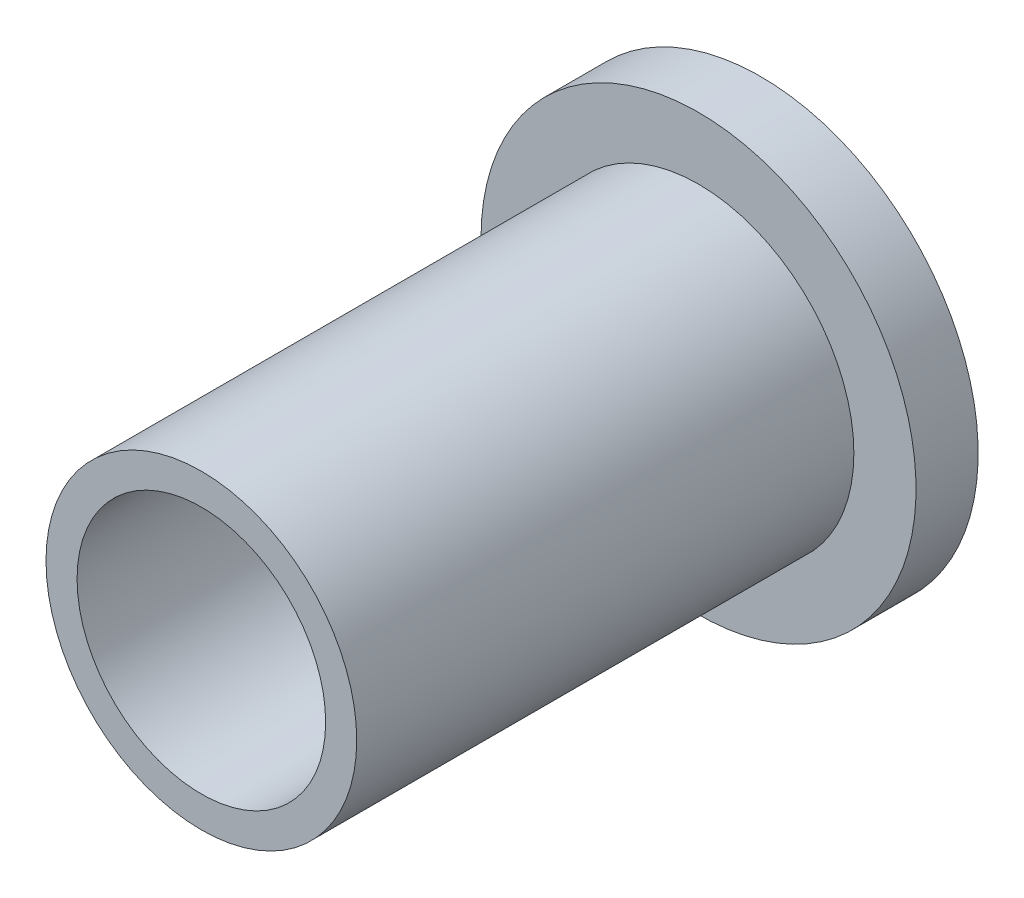
from build123d import *

# Parameters (mm, degrees)
SKETCH1_R           = 7.9375
SKETCH1_R_2         = 6.35
BOSS_EXTRUDE1_DEPTH = 25.4
SKETCH2_R           = 11.1125
SKETCH2_R_2         = 6.35
BOSS_EXTRUDE2_DEPTH = 3.175


with BuildPart() as part:
    # Sketch1 → Boss-Extrude1 (new body)
    with BuildSketch(Plane.XY):
        Circle(SKETCH1_R)
        Circle(SKETCH1_R_2, mode=Mode.SUBTRACT)
    extrude(amount=BOSS_EXTRUDE1_DEPTH)

    # Sketch2 → Boss-Extrude2 (add)
    with BuildSketch(Plane(origin=(0, 0, 0), x_dir=(-1, 0, 0), z_dir=(0, 0, -1))):
        Circle(SKETCH2_R)
        Circle(SKETCH2_R_2, mode=Mode.SUBTRACT)
    extrude(amount=BOSS_EXTRUDE2_DEPTH)


solid = part.part
